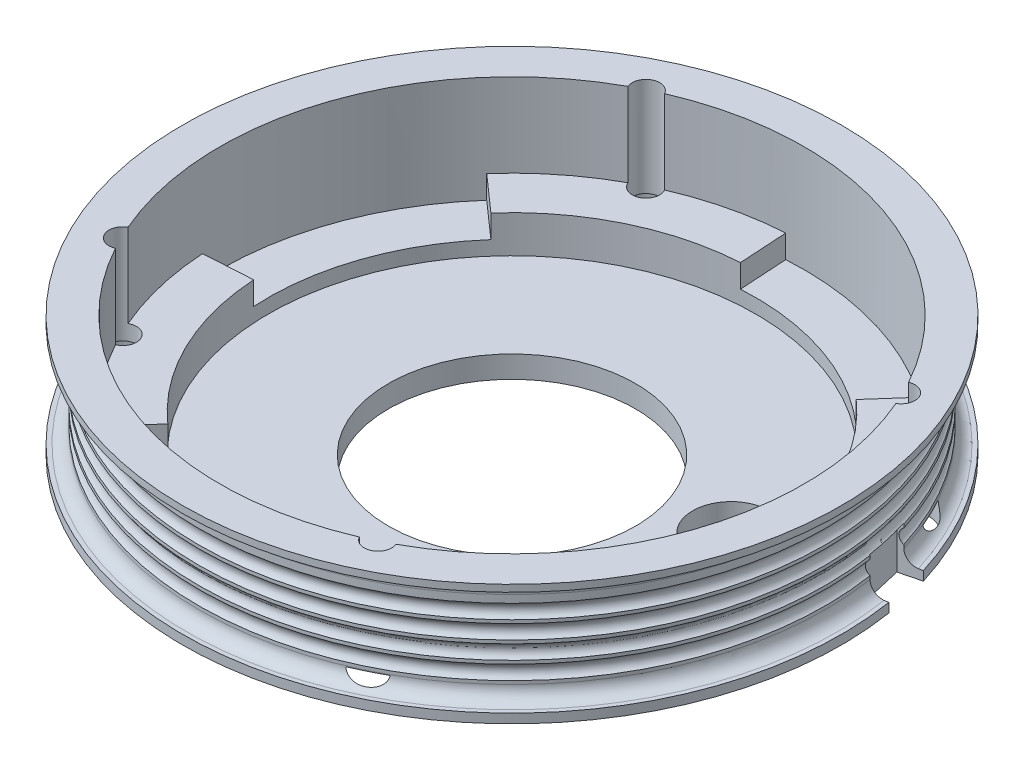
from build123d import *

# Parameters (mm, degrees)
SKETCH1_R                = 23
BOSS_EXTRUDE1_DEPTH      = 2
SKETCH2_R                = 30
SKETCH2_R_2              = 22.2
BOSS_EXTRUDE2_DEPTH      = 11
SKETCH3_R                = 11.25
CUT_EXTRUDE1_DEPTH       = 10
CUT_EXTRUDE8_DEPTH       = 5.5
SKETCH5_R                = 1.25
CUT_EXTRUDE3_DEPTH       = 45.373415465
SKETCH8_R                = 2.5
CUT_EXTRUDE5_DEPTH       = 2
BOSS_EXTRUDE3_DEPTH      = 3
CUT_EXTRUDE9_START       = -3
SKETCH13_R               = 3.5
CUT_EXTRUDE9_DEPTH       = 3
CUT_EXTRUDE10_DEPTH      = 4
CUT_EXTRUDE11_DEPTH      = 10
CUT_EXTRUDE11_DEPTH_BACK = 2.1
SKETCH16_R               = 26.6
CUT_EXTRUDE12_START      = -2.1
CUT_EXTRUDE12_DEPTH      = 2.1


with BuildPart() as part:
    # Sketch1 → Boss-Extrude1 (new body)
    with BuildSketch(Plane(origin=(0, 0, 0), x_dir=(1, 0, 0), z_dir=(0, 1, 0))):
        Circle(SKETCH1_R)
    extrude(amount=-BOSS_EXTRUDE1_DEPTH)

    # Sketch2 → Boss-Extrude2 (add)
    with BuildSketch(Plane(origin=(0, 0, 0), x_dir=(1, 0, 0), z_dir=(0, 1, 0))):
        Circle(SKETCH2_R)
        Circle(SKETCH2_R_2, mode=Mode.SUBTRACT)
    extrude(amount=BOSS_EXTRUDE2_DEPTH)

    # Sketch3 → Cut-Extrude1 (cut)
    with BuildSketch(Plane(origin=(0, 0, 0), x_dir=(1, 0, 0), z_dir=(0, 1, 0))):
        Circle(SKETCH3_R)
    extrude(amount=-CUT_EXTRUDE1_DEPTH, mode=Mode.SUBTRACT)

    # Sketch10 → Cut-Extrude8 (cut)
    with BuildSketch(Plane(origin=(0, 11, 0), x_dir=(1, 0, 0), z_dir=(0, 1, 0))):
        Polygon((8.200315972, -23.949003355), (8.095646912, -20.796423541), (10.150000757, -23.190028641), (9.785351218, -20.056859988), (12.030350745, -22.272642516), (11.408211652, -19.180287743), (13.828521239, -21.20311166), (12.953142433, -18.172694685), (15.532228911, -19.988742051), (14.409590117, -17.040963696), (17.12983571, -18.637829065), (15.76760569, -15.792825644), (18.610428362, -17.159600809), (17.017912527, -14.43680658), (19.963892917, -15.564155079), (18.151969766, -12.982169489), (21.18098384, -13.862390389), (19.162030646, -11.438851016), (22.253387167, -12.065931515), (20.041195426, -9.817393592), (23.173777294, -10.187050095), (20.78345852, -8.128873414), (23.935867025, -8.238580793), (21.383749518, -6.384824789), (24.534450513, -6.233833631), (21.837967824, -4.597161336), (24.965438827, -4.186503063), (22.143010666, -2.77809461), (25.225887879, -2.110574435), (22.296794293, -0.940050681), (25.314018538, -0.020228443), (22.298268206, 0.904414747), (25.229228782, 2.070255729), (22.147422337, 2.742702106), (24.972097812, 4.146597956), (21.845287117, 4.562254028), (24.544382092, 6.194614714), (21.393926434, 6.350641129), (23.949003355, 8.200315972), (20.796423541, 8.095646912), (23.190028641, 10.150000757), (20.056859988, 9.785351218), (22.272642516, 12.030350745), (19.180287743, 11.408211652), (21.20311166, 13.828521239), (18.172694685, 12.953142433), (19.988742051, 15.532228911), (17.040963696, 14.409590117), (18.637829065, 17.12983571), (15.792825644, 15.76760569), (17.159600809, 18.610428362), (14.43680658, 17.017912527), (15.564155079, 19.963892917), (12.982169489, 18.151969766), (13.862390389, 21.18098384), (11.438851016, 19.162030646), (12.065931515, 22.253387167), (9.817393592, 20.041195426), (10.187050095, 23.173777294), (8.128873414, 20.78345852), (8.238580793, 23.935867025), (6.384824789, 21.383749518), (6.233833631, 24.534450513), (4.597161336, 21.837967824), (4.186503063, 24.965438827), (2.77809461, 22.143010666), (2.110574435, 25.225887879), (0.940050681, 22.296794293), (0.020228443, 25.314018538), (-0.904414747, 22.298268206), (-2.070255729, 25.229228782), (-2.742702106, 22.147422337), (-4.146597956, 24.972097812), (-4.562254028, 21.845287117), (-6.194614714, 24.544382092), (-6.350641129, 21.393926434), (-8.200315972, 23.949003355), (-8.095646912, 20.796423541), (-10.150000757, 23.190028641), (-9.785351218, 20.056859988), (-12.030350745, 22.272642516), (-11.408211652, 19.180287743), (-13.828521239, 21.20311166), (-12.953142433, 18.172694685), (-15.532228911, 19.988742051), (-14.409590117, 17.040963696), (-17.12983571, 18.637829065), (-15.76760569, 15.792825644), (-18.610428362, 17.159600809), (-17.017912527, 14.43680658), (-19.963892917, 15.564155079), (-18.151969766, 12.982169489), (-21.18098384, 13.862390389), (-19.162030646, 11.438851016), (-22.253387167, 12.065931515), (-20.041195426, 9.817393592), (-23.173777294, 10.187050095), (-20.78345852, 8.128873414), (-23.935867025, 8.238580793), (-21.383749518, 6.384824789), (-24.534450513, 6.233833631), (-21.837967824, 4.597161336), (-24.965438827, 4.186503063), (-22.143010666, 2.77809461), (-25.225887879, 2.110574435), (-22.296794293, 0.940050681), (-25.314018538, 0.020228443), (-22.298268206, -0.904414747), (-25.229228782, -2.070255729), (-22.147422337, -2.742702106), (-24.972097812, -4.146597956), (-21.845287117, -4.562254028), (-24.544382092, -6.194614714), (-21.393926434, -6.350641129), (-23.949003355, -8.200315972), (-20.796423541, -8.095646912), (-23.190028641, -10.150000757), (-20.056859988, -9.785351218), (-22.272642516, -12.030350745), (-19.180287743, -11.408211652), (-21.20311166, -13.828521239), (-18.172694685, -12.953142433), (-19.988742051, -15.532228911), (-17.040963696, -14.409590118), (-18.637829065, -17.12983571), (-15.792825644, -15.76760569), (-17.159600809, -18.610428362), (-14.43680658, -17.017912527), (-15.564155079, -19.963892917), (-12.982169489, -18.151969766), (-13.862390389, -21.18098384), (-11.438851016, -19.162030646), (-12.065931515, -22.253387167), (-9.817393592, -20.041195426), (-10.187050095, -23.173777294), (-8.128873414, -20.78345852), (-8.238580793, -23.935867025), (-6.384824789, -21.383749518), (-6.233833631, -24.534450513), (-4.597161336, -21.837967824), (-4.186503063, -24.965438827), (-2.77809461, -22.143010666), (-2.110574435, -25.225887879), (-0.940050681, -22.296794293), (-0.020228443, -25.314018538), (0.904414747, -22.298268206), (2.070255729, -25.229228782), (2.742702106, -22.147422337), (4.146597956, -24.972097812), (4.562254028, -21.845287117), (6.194614714, -24.544382092), (6.350641129, -21.393926434), align=None)
    extrude(amount=-CUT_EXTRUDE8_DEPTH, mode=Mode.SUBTRACT)

    # Sketch5 → Cut-Extrude3 (cut, through all)
    with BuildSketch(Plane(origin=(0, 11, 0), x_dir=(1, 0, 0), z_dir=(0, 1, 0))):
        with Locations((23.816653914, 11.619681422)):
            Circle(SKETCH5_R)
        with Locations((11.619681422, -23.816653914)):
            Circle(SKETCH5_R)
        with Locations((-23.816653914, -11.619681422)):
            Circle(SKETCH5_R)
        with Locations((-11.619681422, 23.816653914)):
            Circle(SKETCH5_R)
    extrude(amount=-CUT_EXTRUDE3_DEPTH, mode=Mode.SUBTRACT)

    # Sketch8 → Cut-Extrude5 (cut)
    with BuildSketch(Plane(origin=(0, 0, 0), x_dir=(-1, 0, 0), z_dir=(0, -1, 0))):
        with Locations((-23.816653914, 11.619681422)):
            Circle(SKETCH8_R)
        with Locations((11.619681422, 23.816653914)):
            Circle(SKETCH8_R)
        with Locations((23.816653914, -11.619681422)):
            Circle(SKETCH8_R)
        with Locations((-11.619681422, -23.816653914)):
            Circle(SKETCH8_R)
    extrude(amount=-CUT_EXTRUDE5_DEPTH, mode=Mode.SUBTRACT)

    # Sketch6 → Cut-Revolve1 (revolve, cut)
    with BuildSketch(Plane(origin=(0, 0, 0), x_dir=(0, 0, -1), z_dir=(1, 0, 0))):
        with BuildLine():
            Line((29.617379965, 10.370057221), (30.175990194, 10.370057221))
            Line((30.175990194, 10.370057221), (30.175990194, 0.844133137))
            Line((30.175990194, 0.844133137), (29.617379965, 0.844133137))
            ThreePointArc((29.617379965, 0.844133137), (28.845207332, 1.248305666), (28.535847949, 2.063107961))
            Line((28.535847949, 2.063107961), (28.535847949, 2.370192025))
            ThreePointArc((28.535847949, 2.370192025), (28.166100623, 3.016649993), (28.535847949, 3.663107961))
            Line((28.535847949, 3.663107961), (28.535847949, 3.970192025))
            ThreePointArc((28.535847949, 3.970192025), (28.166100623, 4.616649993), (28.535847949, 5.263107961))
            Line((28.535847949, 5.263107961), (28.535847949, 5.570192025))
            ThreePointArc((28.535847949, 5.570192025), (28.166100623, 6.216649993), (28.535847949, 6.863107961))
            Line((28.535847949, 6.863107961), (28.535847949, 7.170192025))
            ThreePointArc((28.535847949, 7.170192025), (28.166100623, 7.816649993), (28.535847949, 8.463107961))
            Line((28.535847949, 8.463107961), (28.535847949, 8.770192025))
            Line((28.535847949, 8.770192025), (28.535847949, 9.151082397))
            ThreePointArc((28.535847949, 9.151082397), (28.845207332, 9.965884692), (29.617379965, 10.370057221))
        make_face()
    revolve(axis=Axis((0, -2, 0), (0, 1, 0)), mode=Mode.SUBTRACT)

    # Sketch12 → Boss-Extrude3 (add)
    with BuildSketch(Plane(origin=(0, -2, 0), x_dir=(-1, 0, 0), z_dir=(0, -1, 0))):
        with BuildLine():
            ThreePointArc((-19.196569326, 5.50814394), (-12.700037344, 3.137602549), (-19.610339715, 3.406145686))
            Line((-19.610339715, 3.406145686), (-22.604401204, 3.986816711))
            ThreePointArc((-22.604401204, 3.986816711), (-22.945534904, 0.596732148), (-22.781071358, -2.806501209))
            Line((-22.781071358, -2.806501209), (-13.282801681, -1.913655237))
            Line((-13.282801681, -1.913655237), (-11.151246895, 7.8263568))
            Line((-11.151246895, 7.8263568), (-19.244527438, 12.510068943))
            ThreePointArc((-19.244527438, 12.510068943), (-20.891029647, 9.50886647), (-22.072877276, 6.296169473))
            Line((-22.072877276, 6.296169473), (-19.196569326, 5.50814394))
        make_face()
    extrude(amount=BOSS_EXTRUDE3_DEPTH)

    # Sketch13 → Cut-Extrude9 (cut)
    with BuildSketch(Plane(origin=(0, -2, 0), x_dir=(-1, 0, 0), z_dir=(0, -1, 0)).offset(CUT_EXTRUDE9_START)):
        with Locations((-16.134136684, 3.813591988)):
            Circle(SKETCH13_R)
    extrude(amount=CUT_EXTRUDE9_DEPTH, mode=Mode.SUBTRACT)

    # Sketch15 → Cut-Extrude10 (cut)
    with BuildSketch(Plane(origin=(0, 0, 0), x_dir=(-1, 0, 0), z_dir=(0, -1, 0))):
        Polygon((-27.685056753, 4.305602049), (-29.062732762, 4.572679608), (-29.895458244, 4.734112549), (-29.095069333, 8.862788139), (-28.130605106, 8.620305944), (-26.766064483, 8.277237952), align=None)
    extrude(amount=-CUT_EXTRUDE10_DEPTH, mode=Mode.SUBTRACT)

    # Sketch16 → Cut-Extrude11 (cut, two sides: drawn at the far end of the back side and taken through both)
    with BuildSketch(Plane(origin=(0, 5.5, 0), x_dir=(1, 0, 0), z_dir=(0, 1, 0)).offset(-CUT_EXTRUDE11_DEPTH_BACK)):
        Circle(SKETCH16_R)
    extrude(amount=CUT_EXTRUDE11_DEPTH + CUT_EXTRUDE11_DEPTH_BACK, mode=Mode.SUBTRACT)

    # Sketch17 → Cut-Extrude12 (cut)
    with BuildSketch(Plane(origin=(0, 3.4, 0), x_dir=(1, 0, 0), z_dir=(0, 1, 0)).offset(CUT_EXTRUDE12_START)):
        with BuildLine():
            ThreePointArc((17.623312569, 19.924328197), (8.657107476, 25.151828764), (-1.627063754, 26.550191403))
            Line((-1.627063754, 26.550191403), (-1.357925388, 22.158430419))
            ThreePointArc((-1.357925388, 22.158430419), (7.225104736, 20.991375885), (14.708178159, 16.62857466))
            Line((14.708178159, 16.62857466), (17.623312569, 19.924328197))
        make_face()
        with BuildLine():
            ThreePointArc((-22.158430419, -1.357925388), (-20.991375885, 7.225104736), (-16.62857466, 14.708178159))
            Line((-16.62857466, 14.708178159), (-19.924328197, 17.623312569))
            ThreePointArc((-19.924328197, 17.623312569), (-25.151828764, 8.657107476), (-26.550191403, -1.627063754))
            Line((-26.550191403, -1.627063754), (-22.158430419, -1.357925388))
        make_face()
        with BuildLine():
            Line((26.550191403, 1.627063754), (22.158430419, 1.357925388))
            ThreePointArc((22.158430419, 1.357925388), (20.991375885, -7.225104736), (16.62857466, -14.708178159))
            Line((16.62857466, -14.708178159), (19.924328197, -17.623312569))
            ThreePointArc((19.924328197, -17.623312569), (25.151828764, -8.657107476), (26.550191403, 1.627063754))
        make_face()
        with BuildLine():
            ThreePointArc((1.357925388, -22.158430419), (-7.225104736, -20.991375885), (-14.708178159, -16.62857466))
            Line((-14.708178159, -16.62857466), (-17.623312569, -19.924328197))
            ThreePointArc((-17.623312569, -19.924328197), (-8.657107476, -25.151828764), (1.627063754, -26.550191403))
            Line((1.627063754, -26.550191403), (1.357925388, -22.158430419))
        make_face()
    extrude(amount=CUT_EXTRUDE12_DEPTH, mode=Mode.SUBTRACT)


solid = part.part
